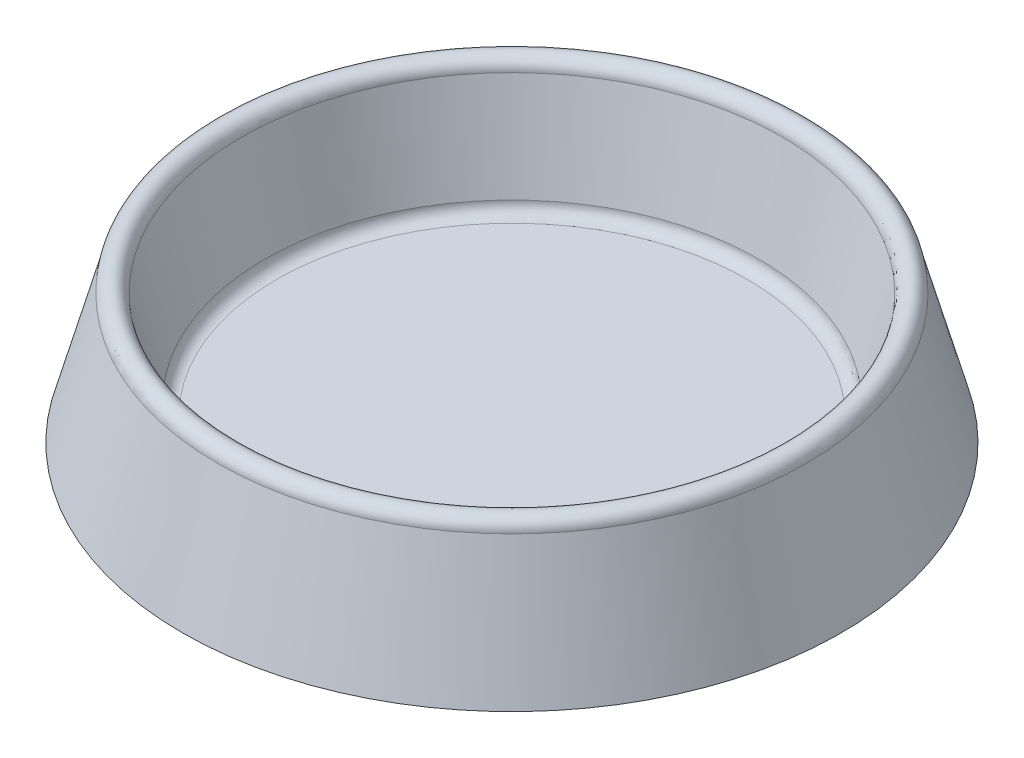
from build123d import *


with BuildPart() as part:
    # Sketch1 → Revolve1 (revolve)
    with BuildSketch(Plane.XY):
        with BuildLine():
            Line((-70, 4.368932039), (0, 4.368932039))
            Line((0, 4.368932039), (0, 9.368932039))
            Line((0, 9.368932039), (-50, 9.368932039))
            ThreePointArc((-50, 9.368932039), (-51.767766953, 10.101165086), (-52.5, 11.868932039))
            Line((-52.5, 11.868932039), (-57.5, 31.747572816))
            ThreePointArc((-57.5, 31.747572816), (-60, 34.247572816), (-62.5, 31.747572816))
            Line((-62.5, 31.747572816), (-70, 4.368932039))
        make_face()
    revolve(axis=Axis((0, 41.844660194, 0), (0, -1, 0)))


solid = part.part
